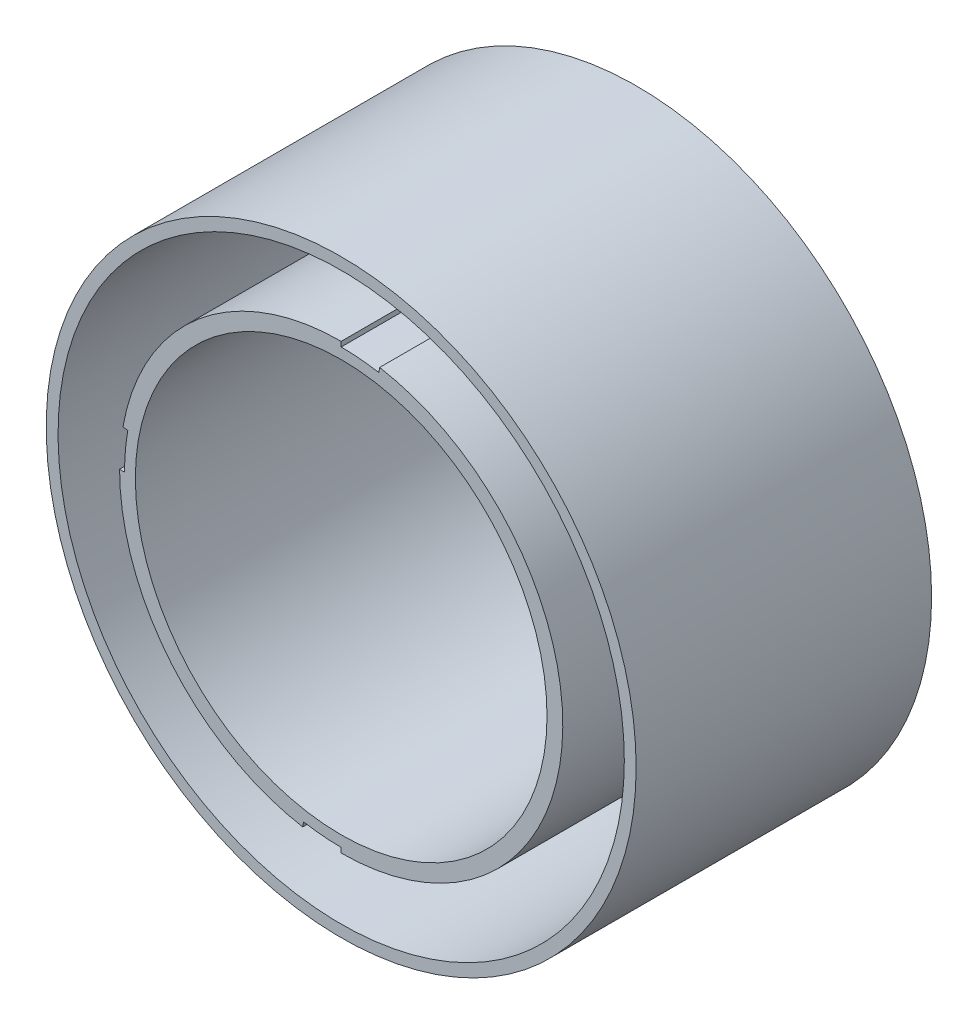
from build123d import *

# Parameters (mm, degrees)
CROQUIS1_R                = 22.5
CROQUIS1_R_2              = 20.9
SALIENTE_EXTRUIR1_DEPTH   = 30
CROQUIS1_R_3              = 29.95
CROQUIS1_R_4              = 28.75
SALIENTE_EXTRUIR1_2_DEPTH = 30
CORTAR_EXTRUIR1_DEPTH     = 30
SALIENTE_EXTRUIR2_DEPTH   = 4


with BuildPart() as part:
    # Croquis1 → Saliente-Extruir1 (new body)
    with BuildSketch(Plane.XY):
        Circle(CROQUIS1_R)
        Circle(CROQUIS1_R_2, mode=Mode.SUBTRACT)
    extrude(amount=SALIENTE_EXTRUIR1_DEPTH)

    # Croquis2 → Cortar-Extruir1 (cut)
    with BuildSketch(Plane.XY.offset(30)):
        with BuildLine():
            ThreePointArc((3.907083998, 22.158174443), (1.961004212, 22.414380707), (0, 22.5))
            Line((0, 22.5), (0, 21.999786926))
            ThreePointArc((0, 21.999786926), (1.91740777, 21.916071095), (3.820222909, 21.66556073))
            Line((3.820222909, 21.66556073), (3.907083998, 22.158174443))
        make_face()
        with BuildLine():
            ThreePointArc((-3.820222909, -21.66556073), (-1.91740777, -21.916071095), (0, -21.999786926))
            Line((0, -21.999786926), (0, -22.5))
            ThreePointArc((0, -22.5), (-1.961004212, -22.414380707), (-3.907083998, -22.158174443))
            Line((-3.907083998, -22.158174443), (-3.820222909, -21.66556073))
        make_face()
        with BuildLine():
            ThreePointArc((-22.158174443, 3.907083998), (-22.414380707, 1.961004212), (-22.5, 0))
            Line((-22.5, 0), (-21.999786926, 0))
            ThreePointArc((-21.999786926, 0), (-21.916071095, 1.91740777), (-21.66556073, 3.820222909))
            Line((-21.66556073, 3.820222909), (-22.158174443, 3.907083998))
        make_face()
    extrude(amount=-CORTAR_EXTRUIR1_DEPTH, mode=Mode.SUBTRACT)



with BuildPart() as body_2:
    # Croquis1 → Saliente-Extruir1 2 (new body)
    with BuildSketch(Plane.XY):
        Circle(CROQUIS1_R_3)
        Circle(CROQUIS1_R_4, mode=Mode.SUBTRACT)
    extrude(amount=SALIENTE_EXTRUIR1_2_DEPTH)


with BuildPart() as part_1:
    add(part.part)

    add(body_2.part)  # Saliente-Extruir2 merges body 2
    # Croquis3 → Saliente-Extruir2 (add)
    with BuildSketch(Plane(origin=(0, 0, 0), x_dir=(-1, 0, 0), z_dir=(0, 0, -1))):
        with BuildLine():
            ThreePointArc((-18.484895437, 12.828041187), (-15.909902577, 15.909902577), (-12.828041187, 18.484895437))
            Line((-12.828041187, 18.484895437), (-18.159694516, 23.816548765))
            Line((-18.159694516, 23.816548765), (-23.816548765, 18.159694516))
            Line((-23.816548765, 18.159694516), (-18.484895437, 12.828041187))
        make_face()
        with BuildLine():
            Line((-18.159694516, -23.816548765), (-12.828041187, -18.484895437))
            ThreePointArc((-12.828041187, -18.484895437), (-15.909902577, -15.909902577), (-18.484895437, -12.828041187))
            Line((-18.484895437, -12.828041187), (-23.816548765, -18.159694516))
            Line((-23.816548765, -18.159694516), (-18.159694516, -23.816548765))
        make_face()
        with BuildLine():
            Line((23.816548765, -18.159694516), (18.484895437, -12.828041187))
            ThreePointArc((18.484895437, -12.828041187), (15.909902577, -15.909902577), (12.828041187, -18.484895437))
            Line((12.828041187, -18.484895437), (18.159694516, -23.816548765))
            Line((18.159694516, -23.816548765), (23.816548765, -18.159694516))
        make_face()
        with BuildLine():
            Line((18.484895437, 12.828041187), (23.816548765, 18.159694516))
            Line((23.816548765, 18.159694516), (18.159694516, 23.816548765))
            Line((18.159694516, 23.816548765), (12.828041187, 18.484895437))
            ThreePointArc((12.828041187, 18.484895437), (15.909902577, 15.909902577), (18.484895437, 12.828041187))
        make_face()
    extrude(amount=-SALIENTE_EXTRUIR2_DEPTH)


solid = part_1.part
